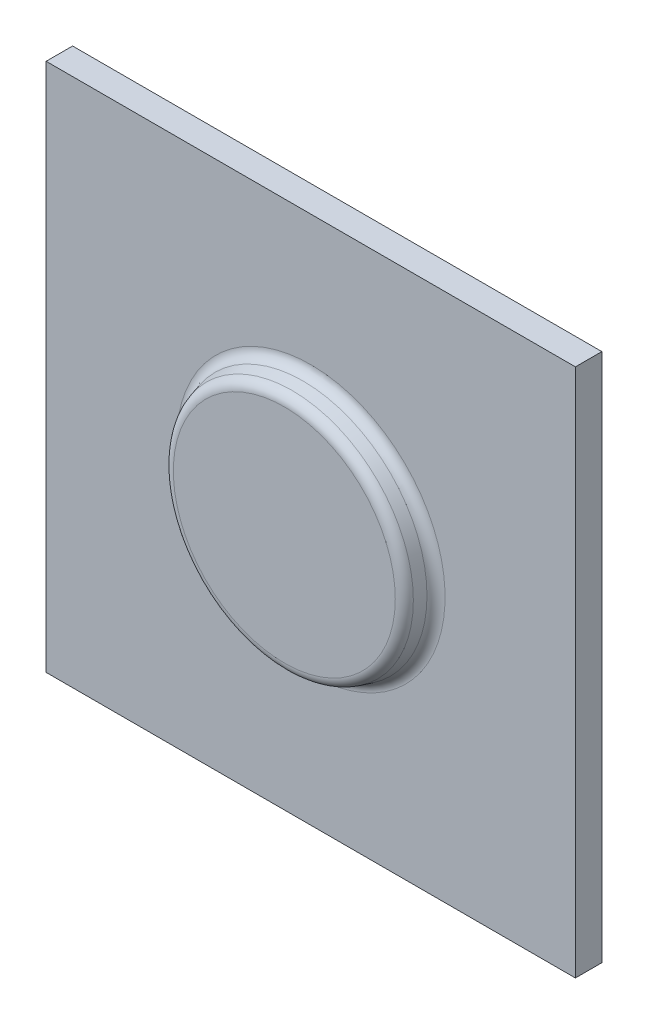
from build123d import *

# Parameters (mm, degrees)
SKETCH_1_W      = 100
SKETCH_1_H      = 100
EXTRUDE_1_DEPTH = 5
SKETCH_2_R      = 22.5
EXTRUDE_2_DEPTH = 5
DRAFT_1_ANGLE   = 15
FILLET_1_R      = 2


with BuildPart() as part:
    # 草图1 → 凸台-拉伸1 (new body)
    with BuildSketch(Plane.XY):
        Rectangle(SKETCH_1_W, SKETCH_1_H)
    extrude(amount=EXTRUDE_1_DEPTH)

    # 草图2 → 凸台-拉伸2 (add)
    with BuildSketch(Plane.XY.offset(5)):
        Circle(SKETCH_2_R)
    extrude(amount=EXTRUDE_2_DEPTH)

    # 拔模1
    draft_1_faces = [part.faces().sort_by_distance(p)[0] for p in [
        (-22.5, 0, 7.5),
    ]]
    draft(draft_1_faces, Plane.XY.offset(10), DRAFT_1_ANGLE)

    # 圆角1
    fillet_1_edges = [part.edges().sort_by_distance(p)[0] for p in [
        (-23.839745962, 0, 5),
        (-22.5, 0, 10),
    ]]
    fillet(fillet_1_edges, radius=FILLET_1_R)


solid = part.part
